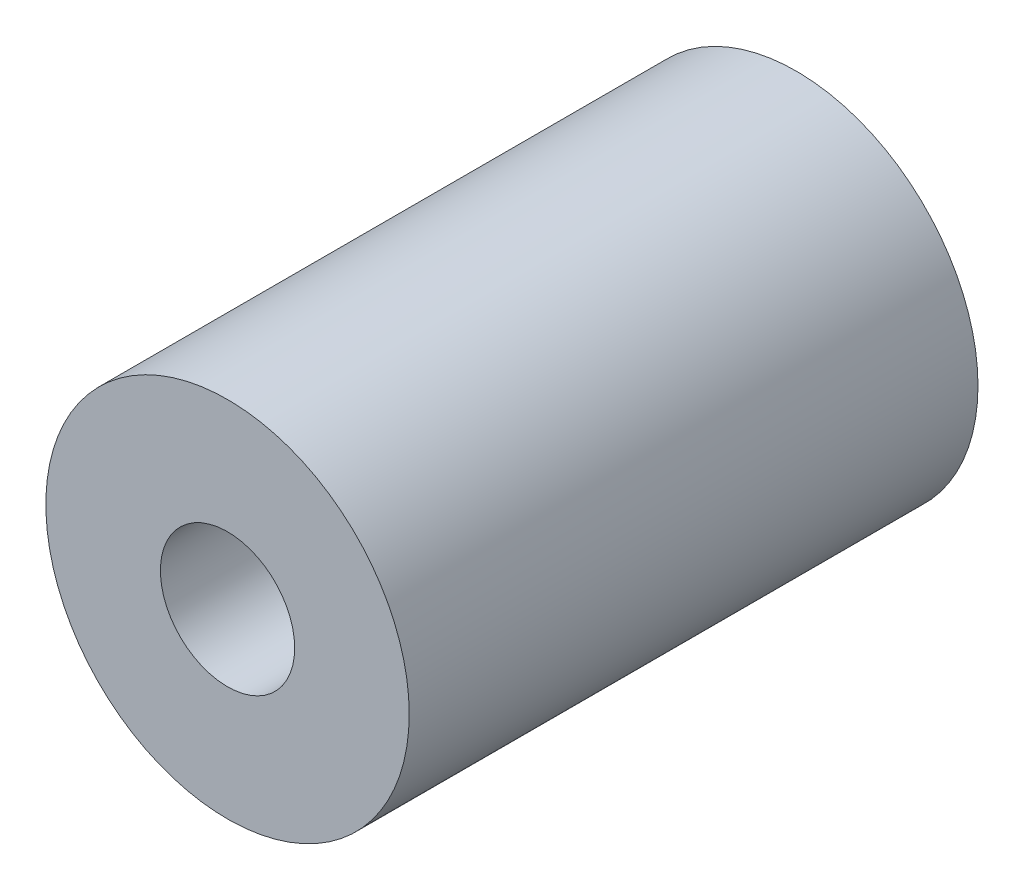
from build123d import *

# Parameters (mm, degrees)
SKETCH1_R           = 2.3
SKETCH1_R_2         = 0.85
BOSS_EXTRUDE1_DEPTH = 7.2


with BuildPart() as part:
    # Sketch1 → Boss-Extrude1 (new body)
    with BuildSketch(Plane.XY):
        Circle(SKETCH1_R)
        Circle(SKETCH1_R_2, mode=Mode.SUBTRACT)
    extrude(amount=BOSS_EXTRUDE1_DEPTH)


solid = part.part
